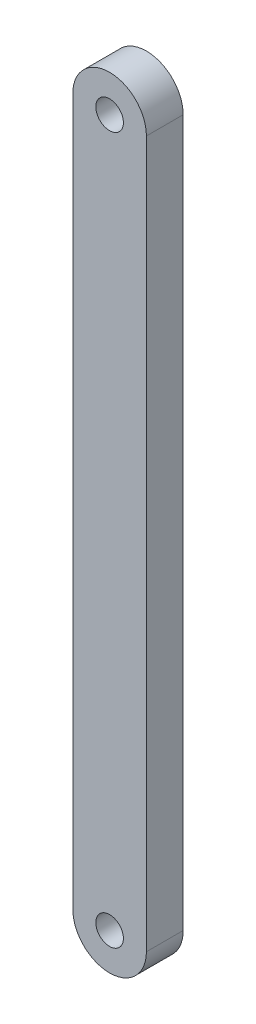
from build123d import *

# Parameters (mm, degrees)
SKETCH1_R           = 4.7625
BOSS_EXTRUDE1_DEPTH = 12.7


with BuildPart() as part:
    # Sketch1 → Boss-Extrude1 (new body)
    with BuildSketch(Plane.XY):
        with BuildLine():
            Line((12.7, 121.92), (12.7, -121.92))
            ThreePointArc((12.7, -121.92), (0, -134.62), (-12.7, -121.92))
            Line((-12.7, -121.92), (-12.7, 121.92))
            ThreePointArc((-12.7, 121.92), (0, 134.62), (12.7, 121.92))
        make_face()
        with Locations((0, 121.92)):
            Circle(SKETCH1_R, mode=Mode.SUBTRACT)
        with Locations((0, -121.92)):
            Circle(SKETCH1_R, mode=Mode.SUBTRACT)
    extrude(amount=BOSS_EXTRUDE1_DEPTH)


solid = part.part
